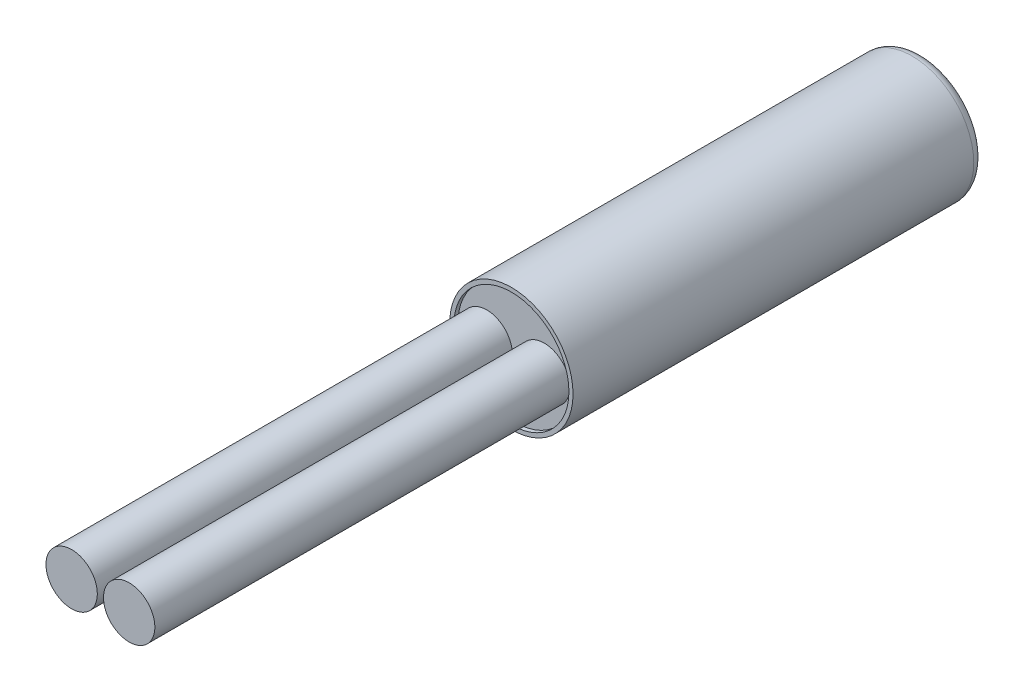
from build123d import *

# Parameters (mm, degrees)
ESQUISSE2_R             = 3
BOSS_EXTRU_1_DEPTH      = 20
CONG_1_R                = 0.5
ESQUISSE3_R             = 2.8
ENL_V_MAT_EXTRU_1_DEPTH = 0.2
ESQUISSE4_R             = 1.25
BOSS_EXTRU_2_DEPTH      = 20.2


with BuildPart() as part:
    # Esquisse2 → Boss.-Extru.1 (new body)
    with BuildSketch(Plane.XY):
        Circle(ESQUISSE2_R)
    extrude(amount=BOSS_EXTRU_1_DEPTH)

    # Congé1
    cong_1_edges = [part.edges().sort_by_distance(p)[0] for p in [
        (-3, 0, 0),
    ]]
    fillet(cong_1_edges, radius=CONG_1_R)

    # Esquisse3 → Enlèv. mat.-Extru.1 (cut)
    with BuildSketch(Plane.XY.offset(20)):
        Circle(ESQUISSE3_R)
    extrude(amount=-ENL_V_MAT_EXTRU_1_DEPTH, mode=Mode.SUBTRACT)

    # Esquisse4 → Boss.-Extru.2 (add)
    with BuildSketch(Plane.XY.offset(19.8)):
        with Locations((-1.4, 0)):
            Circle(ESQUISSE4_R)
        with Locations((1.4, 0)):
            Circle(ESQUISSE4_R)
    extrude(amount=BOSS_EXTRU_2_DEPTH)


solid = part.part
